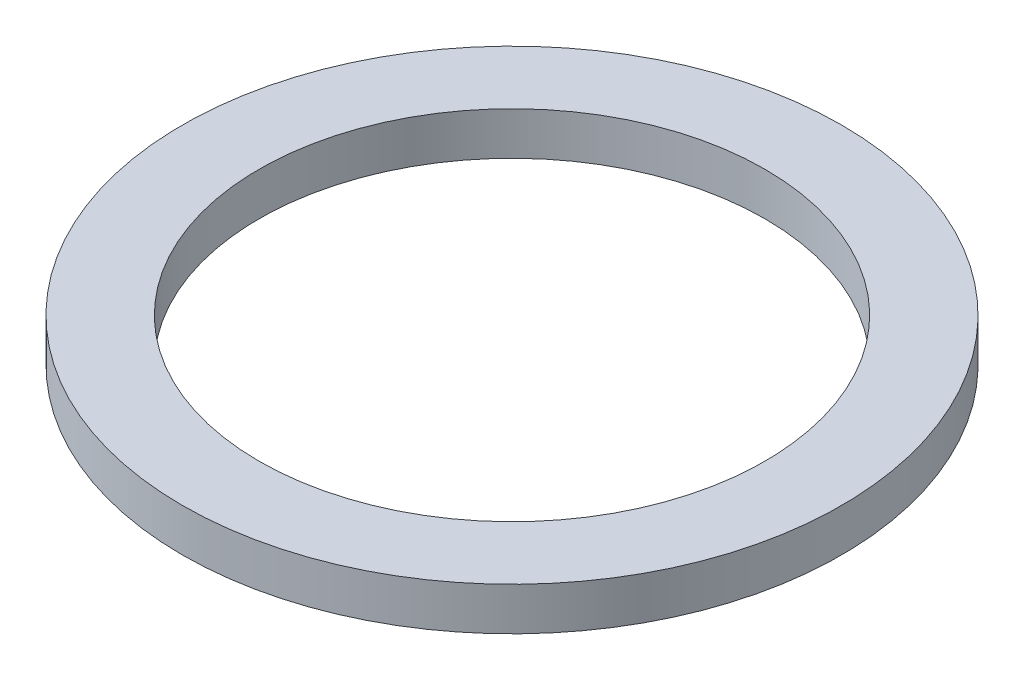
from build123d import *

# Parameters (mm, degrees)
SKETCH1_R           = 21.5
SKETCH1_R_2         = 16.5
BOSS_EXTRUDE1_DEPTH = 2.8


with BuildPart() as part:
    # Sketch1 → Boss-Extrude1 (new body)
    with BuildSketch(Plane(origin=(0, 0, 0), x_dir=(1, 0, 0), z_dir=(0, 1, 0))):
        Circle(SKETCH1_R)
        Circle(SKETCH1_R_2, mode=Mode.SUBTRACT)
    extrude(amount=BOSS_EXTRUDE1_DEPTH)


solid = part.part
